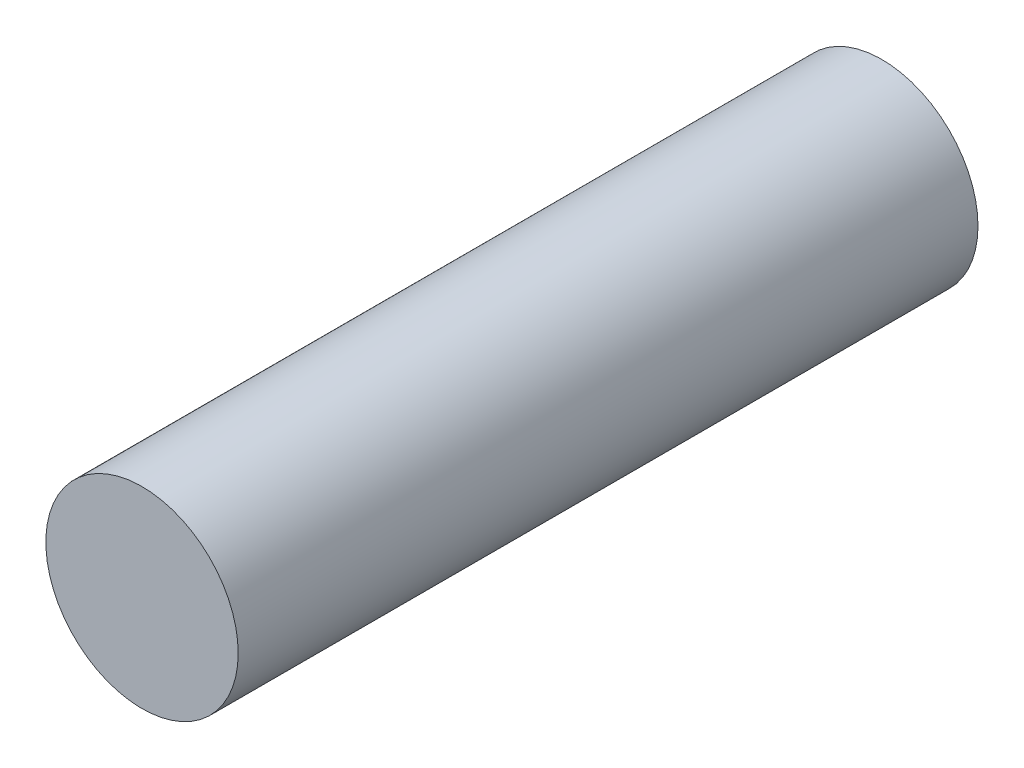
from build123d import *

# Parameters (mm, degrees)
SKETCH1_R           = 6.5
BOSS_EXTRUDE1_DEPTH = 25


with BuildPart() as part:
    # Sketch1 → Boss-Extrude1 (new body, symmetric)
    with BuildSketch(Plane.XY):
        Circle(SKETCH1_R)
    extrude(amount=BOSS_EXTRUDE1_DEPTH, both=True)


solid = part.part
